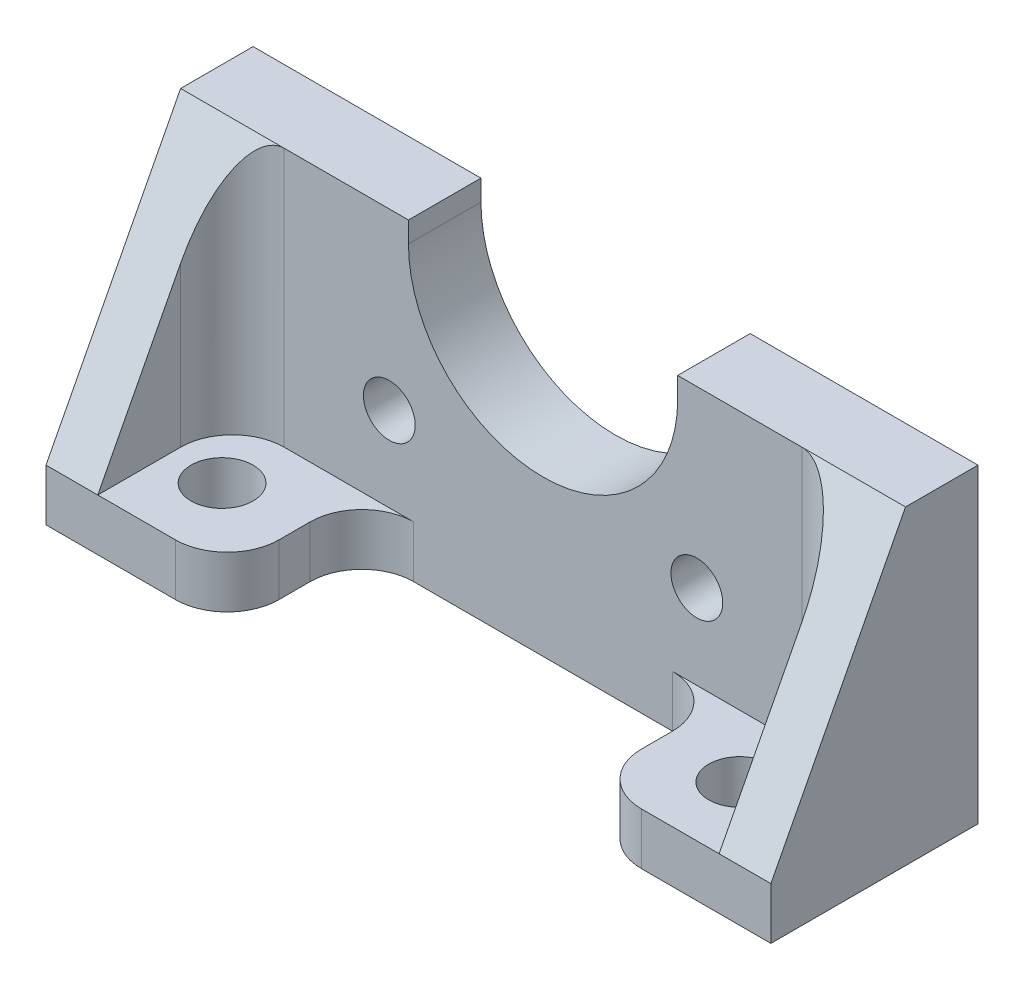
from build123d import *

# Parameters (mm, degrees)
SKETCH1_R           = 2.5
BOSS_EXTRUDE1_DEPTH = 20
CUT_EXTRUDE1_DEPTH  = 71
SKETCH3_R           = 3
CUT_EXTRUDE2_DEPTH  = 31
CUT_EXTRUDE3_START  = -5
CUT_EXTRUDE3_DEPTH  = 26
FILLET1_R           = 5


with BuildPart() as part:
    # Sketch1 → Boss-Extrude1 (new body)
    with BuildSketch(Plane.XY):
        with BuildLine():
            Line((0, 0), (0, 5))
            Line((0, 5), (0, 30))
            Line((0, 30), (22, 30))
            Line((22, 30), (22, 28))
            ThreePointArc((22, 28), (35, 15), (48, 28))
            Line((48, 28), (48, 30))
            Line((48, 30), (70, 30))
            Line((70, 30), (70, 5))
            Line((70, 5), (70, 0))
            Line((70, 0), (0, 0))
        make_face()
        with Locations((20.150757595, 13.150757595)):
            Circle(SKETCH1_R, mode=Mode.SUBTRACT)
        with Locations((49.849242405, 13.150757595)):
            Circle(SKETCH1_R, mode=Mode.SUBTRACT)
    extrude(amount=BOSS_EXTRUDE1_DEPTH)

    # Sketch2 → Cut-Extrude1 (cut, through all)
    with BuildSketch(Plane(origin=(70, 0, 0), x_dir=(0, 0, -1), z_dir=(1, 0, 0))):
        Polygon((-7, 30), (-20, 5), (-20, 30), align=None)
    extrude(amount=-CUT_EXTRUDE1_DEPTH, mode=Mode.SUBTRACT)

    # Sketch3 → Cut-Extrude2 (cut, through all)
    with BuildSketch(Plane.XZ):
        with Locations(Location((10, 13, 0), (0, 0, 270))):  # turned: the seam where the file's is
            Circle(SKETCH3_R)
        with Locations(Location((60, 13, 0), (0, 0, 270))):  # turned: the seam where the file's is
            Circle(SKETCH3_R)
        with BuildLine():
            Line((17.5, 20), (52.5, 20))
            Line((52.5, 20), (52.5, 12))
            ThreePointArc((52.5, 12), (51.035533906, 8.464466094), (47.5, 7))
            Line((47.5, 7), (22.5, 7))
            ThreePointArc((22.5, 7), (18.964466094, 8.464466094), (17.5, 12))
            Line((17.5, 12), (17.5, 20))
        make_face()
    extrude(amount=-CUT_EXTRUDE2_DEPTH, mode=Mode.SUBTRACT)

    # Sketch4 → Cut-Extrude3 (cut, through all)
    with BuildSketch(Plane.XZ.offset(CUT_EXTRUDE3_START)):
        with BuildLine():
            Line((65, 12), (65, 20))
            Line((65, 20), (5, 20))
            Line((5, 20), (5, 12))
            ThreePointArc((5, 12), (6.464466094, 8.464466094), (10, 7))
            Line((10, 7), (60, 7))
            ThreePointArc((60, 7), (63.535533906, 8.464466094), (65, 12))
        make_face()
    extrude(amount=-CUT_EXTRUDE3_DEPTH, mode=Mode.SUBTRACT)

    # Fillet1
    fillet1_edges = [part.edges().sort_by_distance(p)[0] for p in [
        (17.5, 2.5, 20),
        (52.5, 2.5, 20),
    ]]
    fillet(fillet1_edges, radius=FILLET1_R)


solid = part.part
